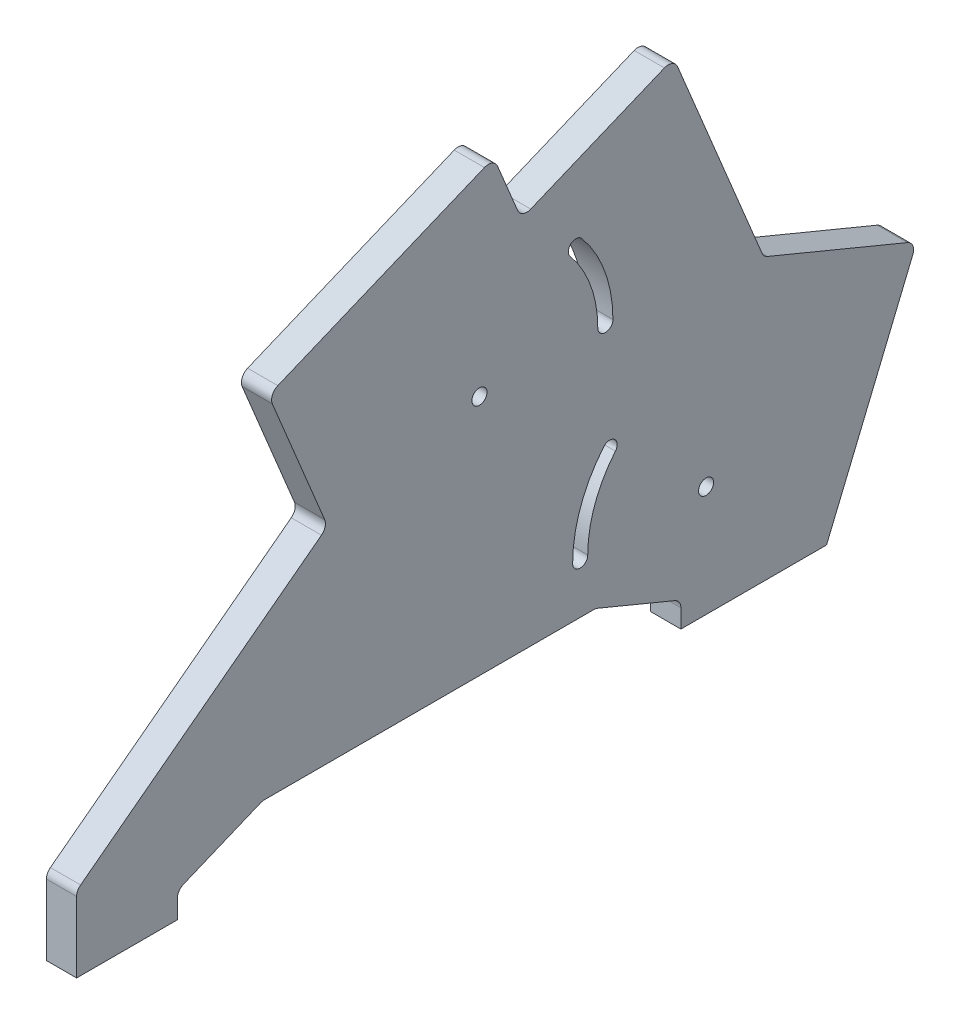
from build123d import *

# Parameters (mm, degrees)
SKETCH1_R                   = 1.5
BOSS_EXTRUDE1_DEPTH         = 6
FILLET1_R                   = 2
TAP_DRILL_FOR_M3_TAP1_D     = 2.5
TAP_DRILL_FOR_M3_TAP1_DEPTH = 10
TAP_DRILL_FOR_M3_TAP1_TIP   = 0.751075774


with BuildPart() as part:
    # Sketch1 → Boss-Extrude1 (new body)
    with BuildSketch(Plane(origin=(0, 0, 0), x_dir=(0, 0, -1), z_dir=(1, 0, 0))):
        Polygon((0, 0), (0, 15), (49.854455432, 52.772847367), (38.110170638, 81.126058999), (82.834388097, 99.651436437), (88.330517158, 86.382607119), (118.575687602, 98.910566914), (136.428533447, 55.809984346), (166.824723678, 43.219470108), (148.922633001, 0), (120, 0), (120, 5), (103.100505063, 12), (36.899494937, 12), (20, 5), (20, 0), align=None)
        with Locations((80, 60)):
            Circle(SKETCH1_R, mode=Mode.SUBTRACT)
        with Locations((125, 22)):
            Circle(SKETCH1_R, mode=Mode.SUBTRACT)
        with BuildLine():
            ThreePointArc((106.5, 60), (104.901854451, 69.063533798), (100.300177743, 77.033871657))
            ThreePointArc((100.300177743, 77.033871657), (98.186929663, 77.218756907), (98.002044413, 75.105508828))
            ThreePointArc((98.002044413, 75.105508828), (102.082776588, 68.037473368), (103.5, 60))
            ThreePointArc((103.5, 60), (105, 58.5), (106.5, 60))
        make_face(mode=Mode.SUBTRACT)
        with BuildLine():
            ThreePointArc((104.699822257, 39.033871657), (100.098145549, 31.063533798), (98.5, 22))
            ThreePointArc((98.5, 22), (100, 20.5), (101.5, 22))
            ThreePointArc((101.5, 22), (102.917223412, 30.037473368), (106.997955587, 37.105508828))
            ThreePointArc((106.997955587, 37.105508828), (106.813070337, 39.218756907), (104.699822257, 39.033871657))
        make_face(mode=Mode.SUBTRACT)
    extrude(amount=BOSS_EXTRUDE1_DEPTH)

    # Fillet1
    fillet1_edges = [part.edges().sort_by_distance(p)[0] for p in [
        (3, 15, 0),
        (3, 52.772847367, -49.854455432),
        (3, 81.126058999, -38.110170638),
        (3, 99.651436437, -82.834388097),
        (3, 86.382607119, -88.330517158),
        (3, 98.910566914, -118.575687602),
        (3, 55.809984346, -136.428533447),
        (3, 43.219470108, -166.824723678),
        (3, 5, -120),
        (3, 12, -103.100505063),
        (3, 12, -36.899494937),
        (3, 5, -20),
    ]]
    fillet(fillet1_edges, radius=FILLET1_R)

    # Tap Drill for M3 Tap1
    with Locations(Plane(origin=(0, 0, 0), x_dir=(-1, 0, 0), z_dir=(0, -1, 0))):
        with Locations((-3, 10), (-3, 130)):
            Hole(TAP_DRILL_FOR_M3_TAP1_D / 2, depth=TAP_DRILL_FOR_M3_TAP1_DEPTH)
            with Locations((0, 0, -(TAP_DRILL_FOR_M3_TAP1_DEPTH + TAP_DRILL_FOR_M3_TAP1_TIP / 2))):  # 118° drill point
                Cone(0, TAP_DRILL_FOR_M3_TAP1_D / 2, TAP_DRILL_FOR_M3_TAP1_TIP, mode=Mode.SUBTRACT)


solid = part.part
